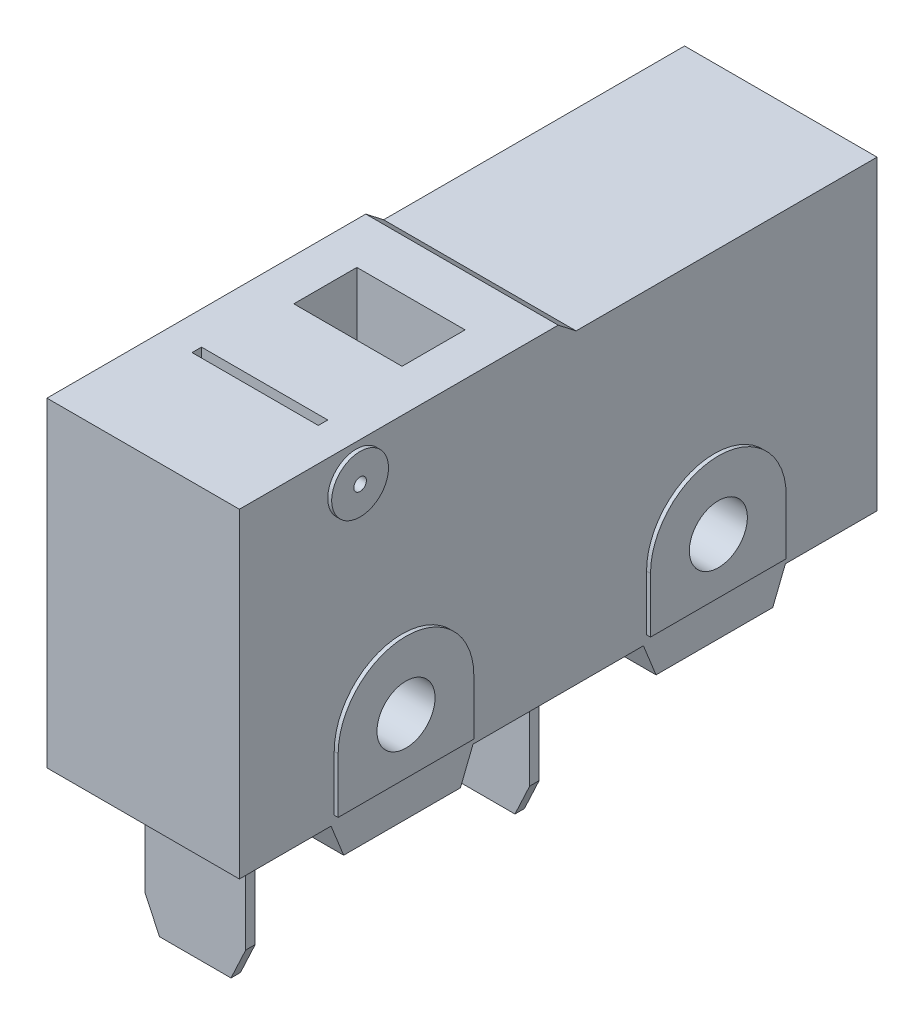
from build123d import *

# Parameters (mm, degrees)
SKETCH1_W               = 20.21
SKETCH1_H               = 9.71
BOSS_EXTRUDE1_DEPTH     = 3.05
BOSS_EXTRUDE2_DEPTH     = 3.05
BOSS_EXTRUDE3_DEPTH     = 3.175
MOUNTING_HOLES_R        = 0.92
CUT_EXTRUDE1_DEPTH      = 4.175
CUT_EXTRUDE1_DEPTH_BACK = 4.175
SKETCH5_R               = 0.9
BOSS_EXTRUDE4_DEPTH     = 3.175
SKETCH6_R               = 0.2
CUT_EXTRUDE2_DEPTH      = 4.175
CUT_EXTRUDE2_DEPTH_BACK = 4.175
SKETCH7_W               = 4
SKETCH7_H               = 0.3
CUT_EXTRUDE3_DEPTH      = 5
SKETCH8_W               = 3.43
SKETCH8_H               = 2
CUT_EXTRUDE4_DEPTH      = 4
SKETCH9_W               = 3.2
SKETCH9_H               = 0.3
BOSS_EXTRUDE5_DEPTH     = 4.5
BOSS_EXTRUDE5_2_DEPTH   = 4.5
CHAMFER1_SIZE           = 1
CHAMFER1_SIZE2          = 0.466307658
CHAMFER1_PART_2_SIZE    = 1
CHAMFER1_PART_2_SIZE2   = 0.466307658
CHAMFER2_SIZE           = 1
CHAMFER2_SIZE2          = 0.466307658
CHAMFER2_PART_2_SIZE    = 1
CHAMFER2_PART_2_SIZE2   = 0.466307658


with BuildPart() as part:
    # Sketch1 → Boss-Extrude1 (new body, symmetric)
    with BuildSketch(Plane(origin=(0, 0, 0), x_dir=(0, 0, -1), z_dir=(1, 0, 0))):
        Rectangle(SKETCH1_W, SKETCH1_H)
    extrude(amount=BOSS_EXTRUDE1_DEPTH, both=True)

    # Sketch4 → Boss-Extrude2 (add, symmetric)
    with BuildSketch(Plane(origin=(0, 0, 0), x_dir=(0, 0, -1), z_dir=(1, 0, 0))):
        Polygon((-7.2, -4.855), (-6.8, -5.855), (-3.1, -5.855), (-2.7, -4.855), align=None)
        Polygon((2.7, -4.855), (7.2, -4.855), (6.8, -5.855), (3.1, -5.855), align=None)
        Polygon((-10.105, 4.855), (-10.105, 5.295), (0, 5.295), (0.566278635, 4.855), align=None)
    extrude(amount=BOSS_EXTRUDE2_DEPTH, both=True)

    # Sketch3 → Boss-Extrude3 (add, symmetric)
    with BuildSketch(Plane(origin=(0, 0, 0), x_dir=(0, 0, -1), z_dir=(1, 0, 0))):
        with BuildLine():
            Line((-7.1, -2.855), (-7.1, -4.605))
            Line((-7.1, -4.605), (-2.8, -4.605))
            Line((-2.8, -4.605), (-2.8, -2.855))
            ThreePointArc((-2.8, -2.855), (-4.95, -0.705), (-7.1, -2.855))
        make_face()
        with BuildLine():
            Line((2.8, -4.605), (2.8, -2.855))
            ThreePointArc((2.8, -2.855), (4.95, -0.705), (7.1, -2.855))
            Line((7.1, -2.855), (7.1, -4.605))
            Line((7.1, -4.605), (2.8, -4.605))
        make_face()
    extrude(amount=BOSS_EXTRUDE3_DEPTH, both=True)

    # Mounting Holes → Cut-Extrude1 (cut, two sides)
    with BuildSketch(Plane(origin=(0, 0, 0), x_dir=(0, 0, -1), z_dir=(1, 0, 0))) as cut_extrude1_sk:
        with Locations((-4.95, -2.855)):
            Circle(MOUNTING_HOLES_R)
        with Locations((4.95, -2.855)):
            Circle(MOUNTING_HOLES_R)
    extrude(amount=CUT_EXTRUDE1_DEPTH, mode=Mode.SUBTRACT)
    extrude(cut_extrude1_sk.sketch, amount=-CUT_EXTRUDE1_DEPTH_BACK, mode=Mode.SUBTRACT)

    # Sketch5 → Boss-Extrude4 (add, symmetric)
    with BuildSketch(Plane(origin=(0, 0, 0), x_dir=(0, 0, -1), z_dir=(1, 0, 0))):
        with Locations((-6.405, 4.195)):
            Circle(SKETCH5_R)
    extrude(amount=BOSS_EXTRUDE4_DEPTH, both=True)

    # Sketch6 → Cut-Extrude2 (cut, two sides)
    with BuildSketch(Plane(origin=(0, 0, 0), x_dir=(0, 0, -1), z_dir=(1, 0, 0))) as cut_extrude2_sk:
        with Locations((-6.405, 4.195)):
            Circle(SKETCH6_R)
    extrude(amount=CUT_EXTRUDE2_DEPTH, mode=Mode.SUBTRACT)
    extrude(cut_extrude2_sk.sketch, amount=-CUT_EXTRUDE2_DEPTH_BACK, mode=Mode.SUBTRACT)

    # Sketch7 → Cut-Extrude3 (cut)
    with BuildSketch(Plane(origin=(0, 5.295, 0), x_dir=(1, 0, 0), z_dir=(0, 1, 0))):
        with Locations((0, -6.405)):
            Rectangle(SKETCH7_W, SKETCH7_H)
    extrude(amount=-CUT_EXTRUDE3_DEPTH, mode=Mode.SUBTRACT)

    # Sketch8 → Cut-Extrude4 (cut)
    with BuildSketch(Plane(origin=(0, 5.295, 0), x_dir=(1, 0, 0), z_dir=(0, 1, 0))):
        with Locations((-0.01148339, -2.605)):
            Rectangle(SKETCH8_W, SKETCH8_H)
    extrude(amount=-CUT_EXTRUDE4_DEPTH, mode=Mode.SUBTRACT)


with BuildPart() as body_2:
    # Sketch9 → Boss-Extrude5 (new body)
    with BuildSketch(Plane.XZ.offset(4.855)):
        with Locations((0, 8.305)):
            Rectangle(SKETCH9_W, SKETCH9_H)
    extrude(amount=BOSS_EXTRUDE5_DEPTH)

    # Chamfer2
    chamfer2_edges = [body_2.edges().sort_by_distance(p)[0] for p in [
        (1.6, -9.355, 8.305),
    ]]
    chamfer2_side = [body_2.faces().sort_by_distance(p)[0] for p in [
        (1.6, -7.105, 8.305),
    ]]
    chamfer(chamfer2_edges, length=CHAMFER2_SIZE, length2=CHAMFER2_SIZE2, reference=chamfer2_side[0])

    # Chamfer2 part 2
    chamfer2_part_2_edges = [body_2.edges().sort_by_distance(p)[0] for p in [
        (-1.6, -9.355, 8.305),
    ]]
    chamfer2_part_2_side = [body_2.faces().sort_by_distance(p)[0] for p in [
        (-1.6, -7.105, 8.305),
    ]]
    chamfer(chamfer2_part_2_edges, length=CHAMFER2_PART_2_SIZE, length2=CHAMFER2_PART_2_SIZE2, reference=chamfer2_part_2_side[0])


with BuildPart() as body_3:
    # Sketch9 → Boss-Extrude5 2 (new body)
    with BuildSketch(Plane.XZ.offset(4.855)):
        with Locations((0, -0.695)):
            Rectangle(SKETCH9_W, SKETCH9_H)
    extrude(amount=BOSS_EXTRUDE5_2_DEPTH)

    # Chamfer1
    chamfer1_edges = [body_3.edges().sort_by_distance(p)[0] for p in [
        (1.6, -9.355, -0.695),
    ]]
    chamfer1_side = [body_3.faces().sort_by_distance(p)[0] for p in [
        (1.6, -7.105, -0.695),
    ]]
    chamfer(chamfer1_edges, length=CHAMFER1_SIZE, length2=CHAMFER1_SIZE2, reference=chamfer1_side[0])

    # Chamfer1 part 2
    chamfer1_part_2_edges = [body_3.edges().sort_by_distance(p)[0] for p in [
        (-1.6, -9.355, -0.695),
    ]]
    chamfer1_part_2_side = [body_3.faces().sort_by_distance(p)[0] for p in [
        (-1.6, -7.105, -0.695),
    ]]
    chamfer(chamfer1_part_2_edges, length=CHAMFER1_PART_2_SIZE, length2=CHAMFER1_PART_2_SIZE2, reference=chamfer1_part_2_side[0])


solid = Compound([part.part, body_2.part, body_3.part])
